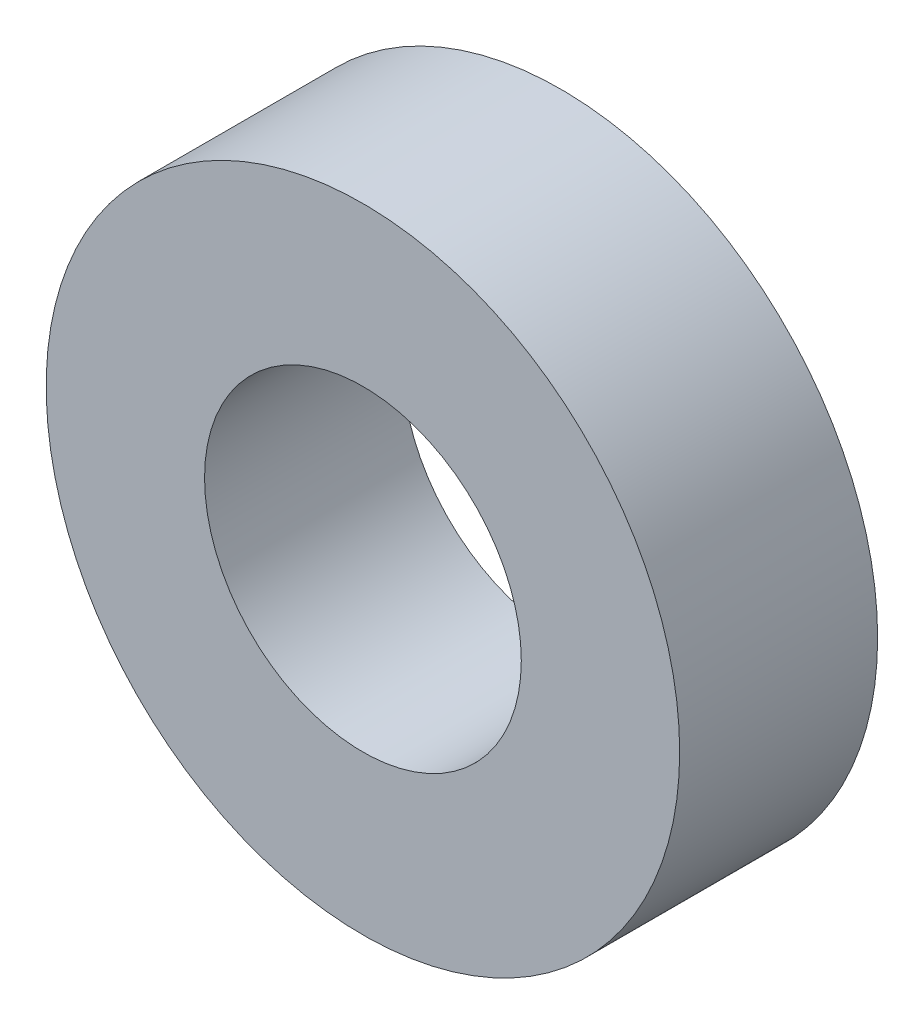
from build123d import *

# Parameters (mm, degrees)
SKETCH_1_R      = 8
SKETCH_1_R_2    = 4
EXTRUDE_1_DEPTH = 5


with BuildPart() as part:
    # 草图1 → 凸台-拉伸1 (new body)
    with BuildSketch(Plane.XY):
        Circle(SKETCH_1_R)
        Circle(SKETCH_1_R_2, mode=Mode.SUBTRACT)
    extrude(amount=EXTRUDE_1_DEPTH)


solid = part.part
